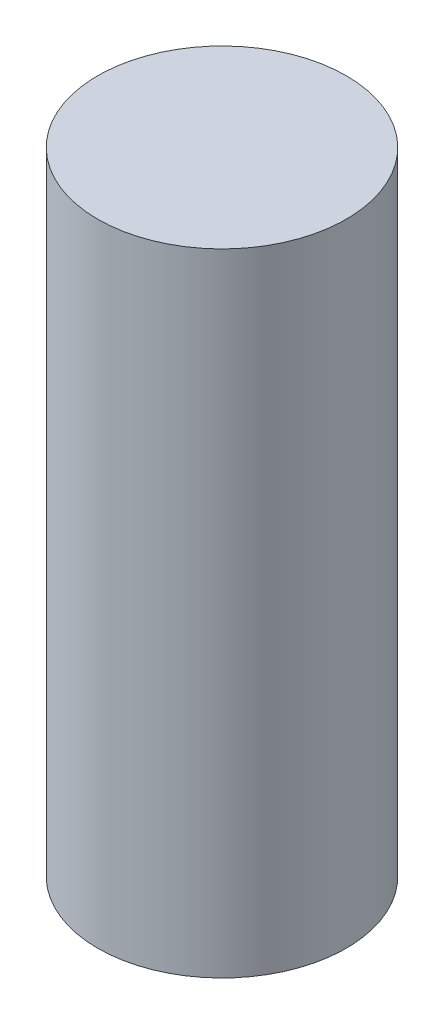
from build123d import *

# Parameters (mm, degrees)
SKETCH1_R      = 1.5
EXTRUDE1_DEPTH = 7.62


with BuildPart() as part:
    # Sketch1 → Extrude1 (new body)
    with BuildSketch(Plane(origin=(0, 0, 0), x_dir=(1, 0, 0), z_dir=(0, 1, 0))):
        with Locations(Location((0, 0, 0), (0, 0, 270))):  # turned: the seam where the file's is
            Circle(SKETCH1_R)
    extrude(amount=EXTRUDE1_DEPTH)


solid = part.part
